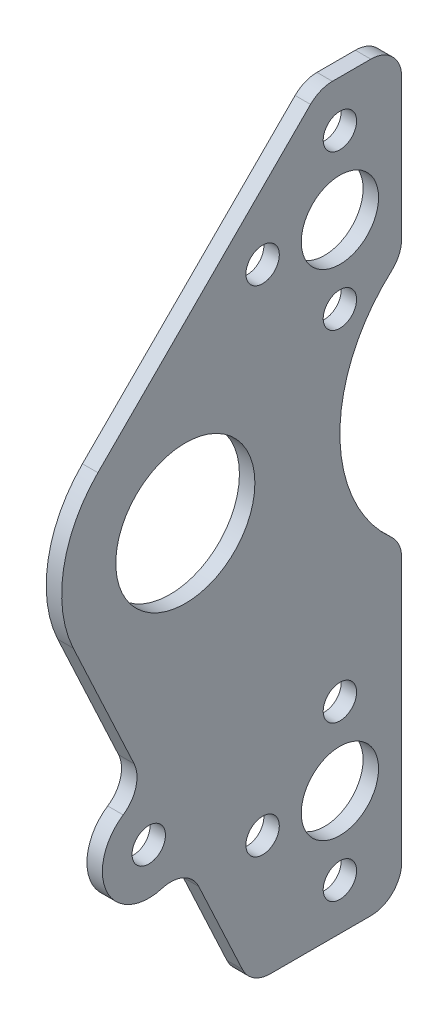
from build123d import *

# Parameters (mm, degrees)
SKETCH1_R           = 14.2875
SKETCH1_R_2         = 7.9375
SKETCH1_R_3         = 3.429
BOSS_EXTRUDE1_DEPTH = 3.175


with BuildPart() as part:
    # Sketch1 → Boss-Extrude1 (new body)
    with BuildSketch(Plane(origin=(0, 0, 0), x_dir=(0, 0, -1), z_dir=(1, 0, 0))):
        with BuildLine():
            Line((25.4, 57.15), (25.4, 28.398063314))
            ThreePointArc((25.4, 28.398063314), (24.8467304, 25.80568667), (23.283333333, 23.665052762))
            ThreePointArc((23.283333333, 23.665052762), (12.7, 0), (23.283333333, -23.665052762))
            ThreePointArc((23.283333333, -23.665052762), (24.8467304, -25.80568667), (25.4, -28.398063314))
            Line((25.4, -28.398063314), (25.4, -82.55))
            ThreePointArc((25.4, -82.55), (23.540128061, -87.040128061), (19.05, -88.9))
            Line((19.05, -88.9), (-1.575652176, -88.9))
            ThreePointArc((-1.575652176, -88.9), (-4.987504689, -87.905535681), (-7.330706623, -85.233625962))
            Line((-7.330706623, -85.233625962), (-16.304501832, -65.989260033))
            ThreePointArc((-16.304501832, -65.989260033), (-19.450268482, -62.883748133), (-23.860481018, -62.583619201))
            ThreePointArc((-23.860481018, -62.583619201), (-35.194449796, -57.475157953), (-31.822423449, -45.509178558))
            ThreePointArc((-31.822423449, -45.509178558), (-29.217505575, -41.937840594), (-29.574405884, -37.53185896))
            Line((-29.574405884, -37.53185896), (-42.070217791, -10.734503848))
            ThreePointArc((-42.070217791, -10.734503848), (-44.064116927, 4.410663713), (-37.010512242, 17.960512242))
            Line((-37.010512242, 17.960512242), (6.669103576, 61.640128061))
            ThreePointArc((6.669103576, 61.640128061), (8.729191841, 63.016635031), (11.159231637, 63.5))
            Line((11.159231637, 63.5), (19.05, 63.5))
            ThreePointArc((19.05, 63.5), (23.540128061, 61.640128061), (25.4, 57.15))
        make_face()
        with Locations((-19.05, 0)):
            Circle(SKETCH1_R, mode=Mode.SUBTRACT)
        with Locations((12.7, 38.1)):
            Circle(SKETCH1_R_2, mode=Mode.SUBTRACT)
        with Locations((12.7, -63.5)):
            Circle(SKETCH1_R_2, mode=Mode.SUBTRACT)
        with Locations((-26.561868124, -53.44971901)):
            Circle(SKETCH1_R_3, mode=Mode.SUBTRACT)
        with Locations((12.7, 53.975)):
            Circle(SKETCH1_R_3, mode=Mode.SUBTRACT)
        with Locations((-3.175, -63.5)):
            Circle(SKETCH1_R_3, mode=Mode.SUBTRACT)
        with Locations((12.7, -47.625)):
            Circle(SKETCH1_R_3, mode=Mode.SUBTRACT)
        with Locations((12.7, -79.375)):
            Circle(SKETCH1_R_3, mode=Mode.SUBTRACT)
        with Locations((-3.175, 38.1)):
            Circle(SKETCH1_R_3, mode=Mode.SUBTRACT)
        with Locations((12.7, 22.225)):
            Circle(SKETCH1_R_3, mode=Mode.SUBTRACT)
    extrude(amount=BOSS_EXTRUDE1_DEPTH)


solid = part.part
